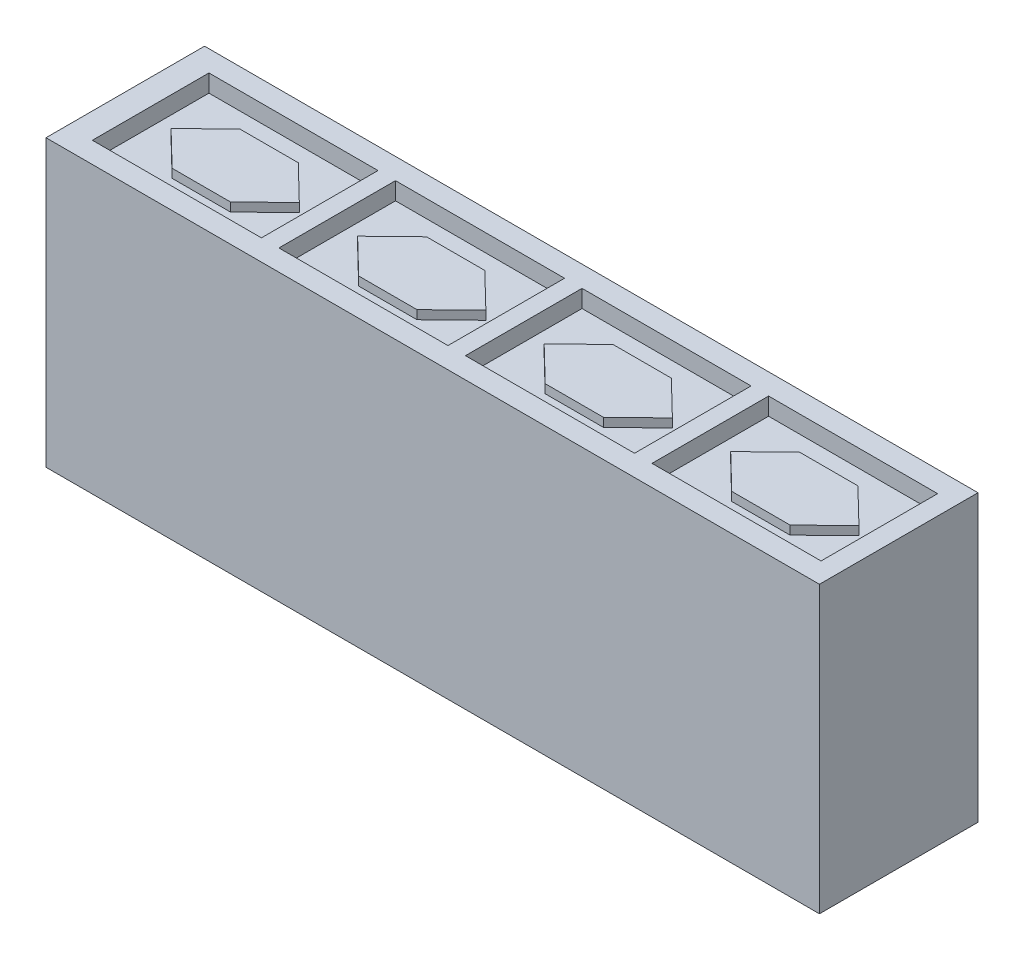
from build123d import *

# Parameters (mm, degrees)
SKETCH2_W           = 132.68
SKETCH2_H           = 48.96
BOSS_EXTRUDE1_DEPTH = 27.2
SKETCH3_W           = 29
SKETCH3_H           = 20
CUT_EXTRUDE1_DEPTH  = 3
SKETCH4_W           = 10
SKETCH4_H           = 11.64
BOSS_EXTRUDE2_DEPTH = 1.5
LPATTERN1_COUNT     = 4
LPATTERN1_PITCH     = 32


with BuildPart() as part:
    # Sketch2 → Boss-Extrude1 (new body)
    with BuildSketch(Plane.XY):
        with Locations((66.34, 24.48)):
            Rectangle(SKETCH2_W, SKETCH2_H)
    extrude(amount=BOSS_EXTRUDE1_DEPTH)

    # Sketch3 → Cut-Extrude1 (cut)
    with BuildSketch(Plane(origin=(0, 48.96, 0), x_dir=(1, 0, 0), z_dir=(0, 1, 0))):
        with Locations((18.855, -13.6)):
            Rectangle(SKETCH3_W, SKETCH3_H)
    cut_extrude1 = extrude(amount=-CUT_EXTRUDE1_DEPTH, mode=Mode.SUBTRACT)

    # Sketch4 → Boss-Extrude2 (add)
    with BuildSketch(Plane(origin=(0, 45.96, 0), x_dir=(1, 0, 0), z_dir=(0, 1, 0))):
        Polygon((13.855, -7.78), (7.855, -13.6), (13.855, -19.42), align=None)
        with Locations((18.855, -13.6)):
            Rectangle(SKETCH4_W, SKETCH4_H)
        Polygon((29.855, -13.6), (23.855, -19.42), (23.855, -7.78), align=None)
    boss_extrude2 = extrude(amount=BOSS_EXTRUDE2_DEPTH)

    # LPattern1: Cut-Extrude1, Boss-Extrude2 ×4
    with Locations(*[(i * LPATTERN1_PITCH, 0, 0) for i in range(1, LPATTERN1_COUNT)]):
        add(cut_extrude1, mode=Mode.SUBTRACT)
        add(boss_extrude2)


solid = part.part
